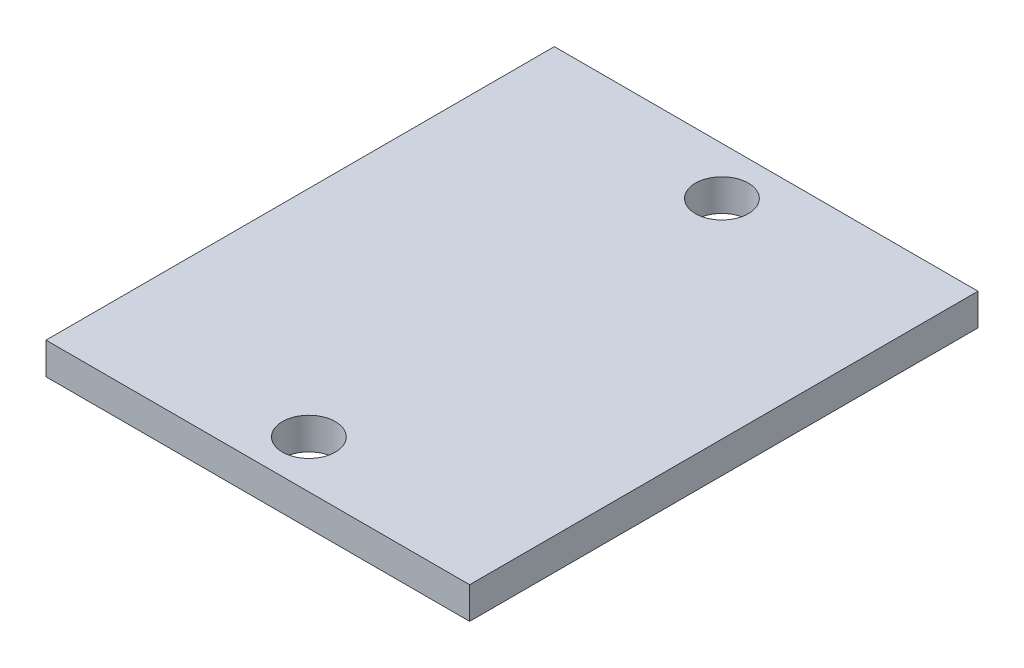
from build123d import *

# Parameters (mm, degrees)
SKETCH2_W           = 20
SKETCH2_H           = 24
SKETCH2_R           = 1.25
BOSS_EXTRUDE1_DEPTH = 1.5


with BuildPart() as part:
    # Sketch2 → Boss-Extrude1 (new body)
    with BuildSketch(Plane(origin=(0, 0, 0), x_dir=(1, 0, 0), z_dir=(0, 1, 0))):
        with Locations((10, -12)):
            Rectangle(SKETCH2_W, SKETCH2_H)
        with Locations((10.16, -2.25)):
            Circle(SKETCH2_R, mode=Mode.SUBTRACT)
        with Locations((10.16, -21.75)):
            Circle(SKETCH2_R, mode=Mode.SUBTRACT)
    extrude(amount=BOSS_EXTRUDE1_DEPTH)


solid = part.part
